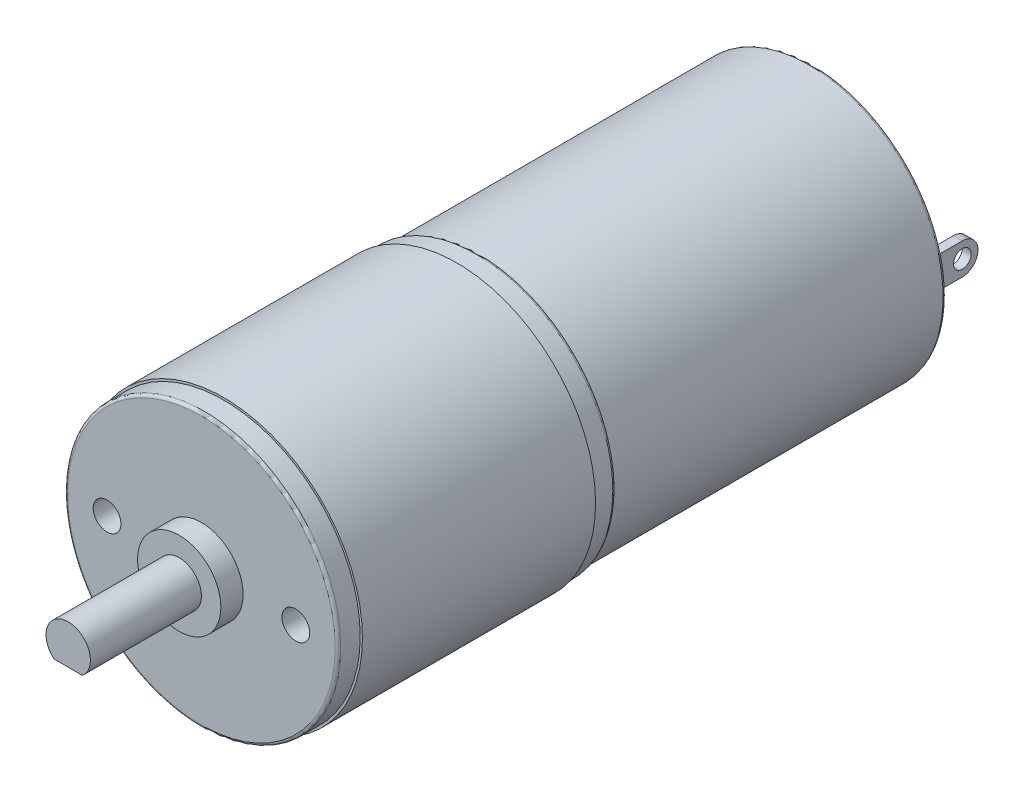
from build123d import *

# Parameters (mm, degrees)
SKETCH1_R                       = 12.3
BOSS_EXTRUDE1_DEPTH             = 2
FILLET1_R                       = 0.25
SKETCH3_R                       = 12.5
BOSS_EXTRUDE3_DEPTH             = 21
SKETCH4_R                       = 12.3
BOSS_EXTRUDE4_DEPTH             = 2
FILLET3_R                       = 0.25
SKETCH5_R                       = 12.05
BOSS_EXTRUDE5_DEPTH             = 30
FILLET4_R                       = 0.25
SKETCH6_W                       = 0.807133711
SKETCH6_H                       = 2.824967988
BOSS_EXTRUDE6_DEPTH             = 5
SKETCH7_R                       = 0.8
CUT_EXTRUDE1_DEPTH              = 23.589171386
SKETCH8_R                       = 2.5
BOSS_EXTRUDE7_DEPTH             = 0.5
SKETCH9_R                       = 3.75
BOSS_EXTRUDE8_DEPTH             = 2
BOSS_EXTRUDE9_DEPTH             = 10
TAP_DRILL_FOR_M3X0_5_TAP1_D     = 2.5
TAP_DRILL_FOR_M3X0_5_TAP1_DEPTH = 10


with BuildPart() as part:
    # Sketch1 → Boss-Extrude1 (new body)
    with BuildSketch(Plane.XY):
        Circle(SKETCH1_R)
    extrude(amount=BOSS_EXTRUDE1_DEPTH)

    # Fillet1
    fillet1_edges = [part.edges().sort_by_distance(p)[0] for p in [
        (-12.3, 0, 2),
    ]]
    fillet(fillet1_edges, radius=FILLET1_R)

    # Sketch3 → Boss-Extrude3 (add)
    with BuildSketch(Plane(origin=(0, 0, 0), x_dir=(-1, 0, 0), z_dir=(0, 0, -1))):
        Circle(SKETCH3_R)
    extrude(amount=BOSS_EXTRUDE3_DEPTH)

    # Sketch4 → Boss-Extrude4 (add)
    with BuildSketch(Plane(origin=(0, 0, -21), x_dir=(-1, 0, 0), z_dir=(0, 0, -1))):
        Circle(SKETCH4_R)
    extrude(amount=BOSS_EXTRUDE4_DEPTH)

    # Fillet3
    fillet3_edges = [part.edges().sort_by_distance(p)[0] for p in [
        (12.3, 0, -23),
    ]]
    fillet(fillet3_edges, radius=FILLET3_R)

    # Sketch5 → Boss-Extrude5 (add)
    with BuildSketch(Plane(origin=(0, 0, -23), x_dir=(-1, 0, 0), z_dir=(0, 0, -1))):
        Circle(SKETCH5_R)
    extrude(amount=BOSS_EXTRUDE5_DEPTH)

    # Fillet4
    fillet4_edges = [part.edges().sort_by_distance(p)[0] for p in [
        (12.05, 0, -53),
    ]]
    fillet(fillet4_edges, radius=FILLET4_R)

    # Sketch6 → Boss-Extrude6 (add)
    with BuildSketch(Plane(origin=(0, 0, -53), x_dir=(-1, 0, 0), z_dir=(0, 0, -1))):
        with Locations((-9.685604531, 0.126114642)):
            Rectangle(SKETCH6_W, SKETCH6_H)
        with Locations((9.685604531, 0.126114642)):
            Rectangle(SKETCH6_W, SKETCH6_H)
    extrude(amount=BOSS_EXTRUDE6_DEPTH)

    # Sketch7 → Cut-Extrude1 (cut, through all)
    with BuildSketch(Plane(origin=(10.089171386, 0, 0), x_dir=(0, 0, -1), z_dir=(1, 0, 0))):
        with Locations((56.439265275, 0.126114642)):
            Circle(SKETCH7_R)
        with BuildLine():
            Line((56.439265275, 1.538598636), (58, 1.538598636))
            Line((58, 1.538598636), (58, -1.286369352))
            Line((58, -1.286369352), (56.439265275, -1.286369352))
            ThreePointArc((56.439265275, -1.286369352), (57.851749269, 0.126114642), (56.439265275, 1.538598636))
        make_face()
    extrude(amount=-CUT_EXTRUDE1_DEPTH, mode=Mode.SUBTRACT)

    # Sketch8 → Boss-Extrude7 (add)
    with BuildSketch(Plane(origin=(0, 0, -53), x_dir=(-1, 0, 0), z_dir=(0, 0, -1))):
        Circle(SKETCH8_R)
    extrude(amount=BOSS_EXTRUDE7_DEPTH)

    # Sketch9 → Boss-Extrude8 (add)
    with BuildSketch(Plane.XY.offset(2)):
        Circle(SKETCH9_R)
    extrude(amount=BOSS_EXTRUDE8_DEPTH)

    # Sketch10 → Boss-Extrude9 (add)
    with BuildSketch(Plane.XY.offset(4)):
        with BuildLine():
            Line((-1.288271492, -1.529822396), (1.262174935, -1.551423357))
            ThreePointArc((1.262174935, -1.551423357), (0.016938357, 1.999928272), (-1.288271492, -1.529822396))
        make_face()
    extrude(amount=BOSS_EXTRUDE9_DEPTH)

    # Tap Drill for M3x0.5 Tap1
    with Locations(Plane.XY.offset(2)):
        with Locations((8.5, 0), (-8.5, 0)):
            Hole(TAP_DRILL_FOR_M3X0_5_TAP1_D / 2, depth=TAP_DRILL_FOR_M3X0_5_TAP1_DEPTH)


solid = part.part
